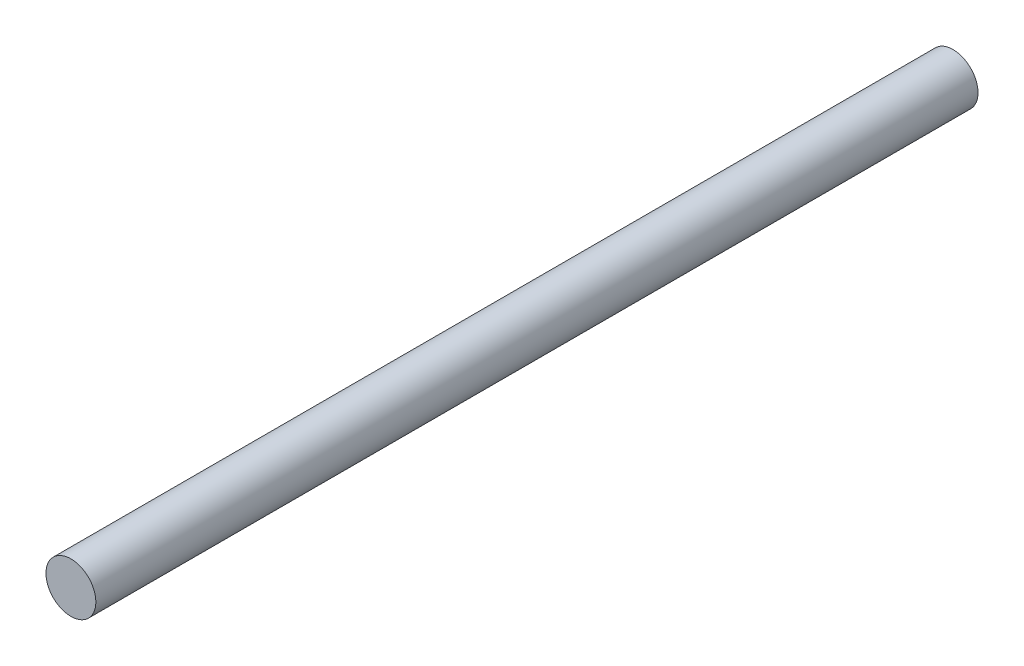
from build123d import *

# Parameters (mm, degrees)
SKETCH1_R           = 12.5
BOSS_EXTRUDE1_DEPTH = 221


with BuildPart() as part:
    # Sketch1 → Boss-Extrude1 (new body, symmetric)
    with BuildSketch(Plane.XY):
        Circle(SKETCH1_R)
    extrude(amount=BOSS_EXTRUDE1_DEPTH, both=True)


solid = part.part
